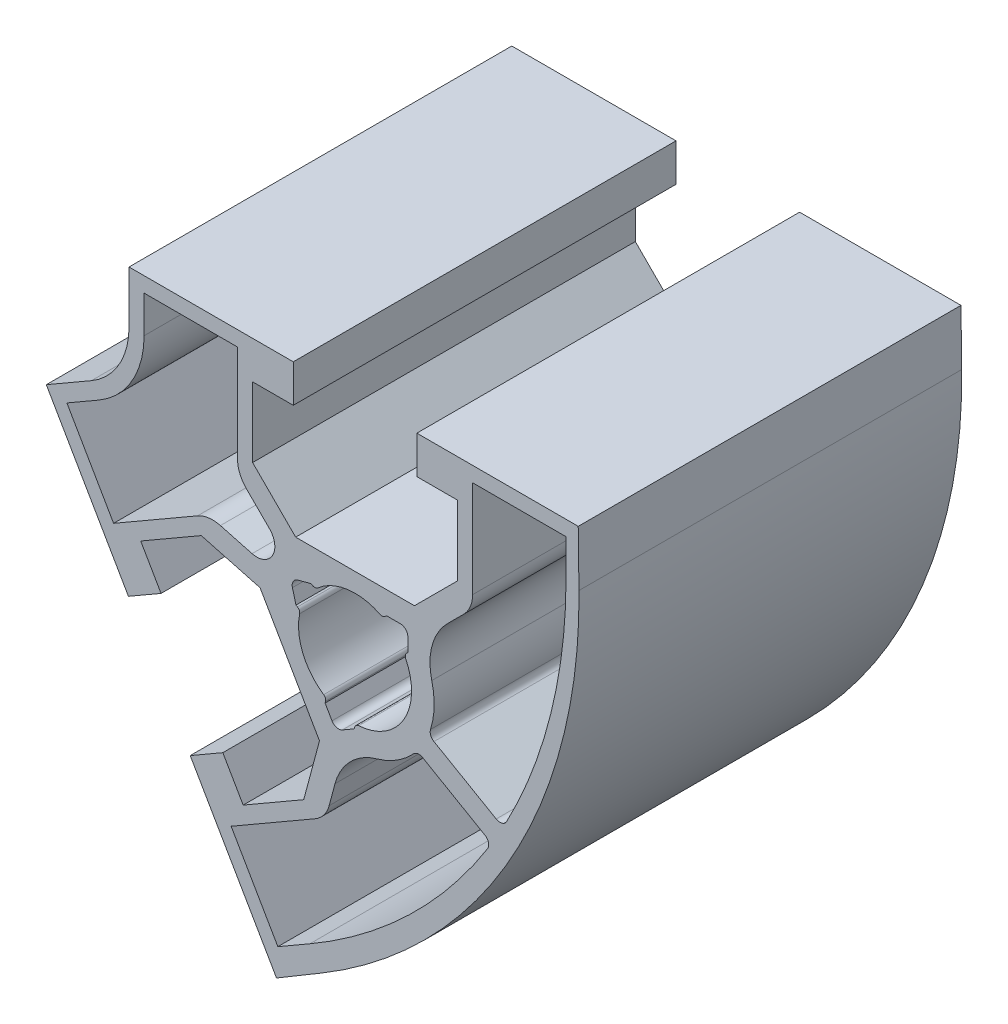
from build123d import *

# Parameters (mm, degrees)
EXTRUSION4_DEPTH = 25.4


with BuildPart() as part:
    # Sketch1 → Extrusion4 (new body)
    with BuildSketch(Plane.XY):
        with BuildLine():
            Line((-14.999999918, 14.999999985), (-4.099998388, 14.999999985))
            Line((-4.099998388, 14.999999985), (-4.099998388, 12.499999985))
            Line((-4.099998388, 12.499999985), (-6.799995338, 12.499999985))
            Line((-6.799995338, 12.499999985), (-6.799995338, 7.860655585))
            Line((-6.799995338, 7.860655585), (-3.941497908, 5.002158155))
            Line((-3.941497908, 5.002158155), (3.941498082, 5.002158155))
            Line((3.941498082, 5.002158155), (6.799995512, 7.860655585))
            Line((6.799995512, 7.860655585), (6.799995512, 12.499999985))
            Line((6.799995512, 12.499999985), (4.099998562, 12.499999985))
            Line((4.099998562, 12.499999985), (4.099998562, 14.999999985))
            Line((4.099998562, 14.999999985), (14.810114901, 14.999999985))
            Line((14.810114901, 14.999999985), (14.858211116, 11.334807121))
            ThreePointArc((14.858211116, 11.334807121), (10.399126577, -6.225213544), (-2.242564242, -19.203095263))
            Line((-2.242564242, -19.203095263), (-5.213160142, -20.9705416))
            Line((-5.213160142, -20.9705416), (-10.940381729, -11.050702829))
            Line((-10.940381729, -11.050702829), (-8.775318226, -9.800702836))
            Line((-8.775318226, -9.800702836), (-7.425319757, -12.138968783))
            Line((-7.425319757, -12.138968783), (-3.407529648, -9.819296585))
            Line((-3.407529648, -9.819296585), (-2.361246978, -5.914516485))
            Line((-2.361246978, -5.914516485), (-6.302744968, 0.912358295))
            Line((-6.302744968, 0.912358295), (-10.207525068, 1.958640965))
            Line((-10.207525068, 1.958640965), (-14.225315169, -0.361031229))
            Line((-14.225315169, -0.361031229), (-12.875316699, -2.699297177))
            Line((-12.875316699, -2.699297177), (-15.040380206, -3.949297173))
            Line((-15.040380206, -3.949297173), (-20.490380962, 5.490381032))
            Line((-20.490380962, 5.490381032), (-17.499999918, 7.216878355))
            ThreePointArc((-17.499999918, 7.216878355), (-15.669872899, 9.047005374), (-14.999999918, 11.547005375))
            Line((-14.999999918, 11.547005375), (-14.999999918, 14.999999985))
        make_face()
        with BuildLine():
            Line((-3.803644053, 2.604283261), (-2.920581563, 2.840899141))
            Line((-2.920581563, 2.840899141), (-2.821802903, 2.783869251))
            ThreePointArc((-2.821802903, 2.783869251), (-2.642326542, 2.745128481), (-2.473891573, 2.818219331))
            ThreePointArc((-2.473891573, 2.818219331), (-0.48947315, 3.717918241), (1.660187067, 3.362481111))
            ThreePointArc((1.660187067, 3.362481111), (1.841800057, 3.335474951), (2.005134057, 3.419347561))
            Line((2.005134057, 3.419347561), (2.085786497, 3.500000001))
            Line((2.085786497, 3.500000001), (3.000000057, 3.500000001))
            ThreePointArc((3.000000057, 3.500000001), (3.353553447, 3.353553391), (3.500000057, 3.000000001))
            Line((3.500000057, 3.000000001), (3.500000057, 2.085786441))
            Line((3.500000057, 2.085786441), (3.419347617, 2.005134001))
            ThreePointArc((3.419347617, 2.005134001), (3.335475004, 1.841799992), (3.362481172, 1.660186995))
            ThreePointArc((3.362481172, 1.660186995), (3.247595339, -1.874999996), (0.243476512, -3.742087545))
            ThreePointArc((0.243476512, -3.742087545), (0.072691963, -3.809506014), (-0.026823118, -3.963808835))
            Line((-0.026823118, -3.963808835), (-0.056343958, -4.073982115))
            Line((-0.056343958, -4.073982115), (-0.848076128, -4.531088895))
            ThreePointArc((-0.848076128, -4.531088895), (-1.227485649, -4.581039105), (-1.531088828, -4.348076195))
            Line((-1.531088828, -4.348076195), (-1.988195608, -3.556344025))
            Line((-1.988195608, -3.556344025), (-1.958674768, -3.446170745))
            ThreePointArc((-1.958674768, -3.446170745), (-1.967705959, -3.262783044), (-2.081900468, -3.119004655))
            ThreePointArc((-2.081900468, -3.119004655), (-3.464548158, -1.435062862), (-3.677595258, 0.733343355))
            ThreePointArc((-3.677595258, 0.733343355), (-3.698514209, 0.915757746), (-3.821802888, 1.051818445))
            Line((-3.821802888, 1.051818445), (-3.920581548, 1.108848335))
            Line((-3.920581548, 1.108848335), (-4.157197428, 1.991910825))
            ThreePointArc((-4.157197428, 1.991910825), (-4.10724722, 2.371320342), (-3.803644053, 2.604283261))
        make_face(mode=Mode.SUBTRACT)
        with BuildLine():
            Line((-13.999999918, 11.547005365), (-13.999999918, 13.999999985))
            Line((-13.999999918, 13.999999985), (-7.799995348, 13.999999985))
            Line((-7.799995348, 13.999999985), (-7.799995348, 7.567762365))
            ThreePointArc((-7.799995348, 7.567762365), (-7.647754416, 6.802395499), (-7.214208908, 6.153548805))
            Line((-7.214208908, 6.153548805), (-5.676298958, 4.615638855))
            ThreePointArc((-5.676298958, 4.615638855), (-5.485596608, 3.167110716), (-6.835409948, 2.607999725))
            Line((-6.835409948, 2.607999725), (-8.936234008, 3.170913835))
            ThreePointArc((-8.936234008, 3.170913835), (-9.714924484, 3.221951904), (-10.453872098, 2.971112985))
            Line((-10.453872098, 2.971112985), (-16.024353279, -0.245005824))
            Line((-16.024353279, -0.245005824), (-19.124355567, 5.124355624))
            Line((-19.124355567, 5.124355624), (-16.999999918, 6.350852945))
            ThreePointArc((-16.999999918, 6.350852945), (-14.803847494, 8.547005366), (-13.999999918, 11.547005365))
        make_face(mode=Mode.SUBTRACT)
        with BuildLine():
            Line((7.799995502, 7.567762365), (7.799995491, 13.999999985))
            Line((7.799995491, 13.999999985), (14.000000062, 13.999999985))
            Line((14.000000062, 13.999999985), (14.000000062, 11.547005385))
            ThreePointArc((14.000000062, 11.547005385), (12.9999649, 3.361510856), (10.058687082, -4.342467065))
            ThreePointArc((10.058687082, -4.342467065), (9.755046631, -4.589262395), (9.366647572, -4.541811055))
            Line((9.366647572, -4.541811055), (5.235555602, -2.156723995))
            ThreePointArc((5.235555602, -2.156723995), (5.019640061, -1.905157444), (5.008550772, -1.573823355))
            ThreePointArc((5.008550772, -1.573823355), (5.247767117, -0.153104957), (5.091786812, 1.279143405))
            ThreePointArc((5.091786812, 1.279143405), (5.115772962, 3.319255937), (6.142816242, 5.082155985))
            Line((6.142816242, 5.082155985), (7.214209062, 6.153548805))
            ThreePointArc((7.214209062, 6.153548805), (7.647754561, 6.802395503), (7.799995502, 7.567762365))
        make_face(mode=Mode.SUBTRACT)
        with BuildLine():
            Line((-1.722025028, -9.324462665), (-1.329868038, -7.860912855))
            ThreePointArc((-1.329868038, -7.860912855), (-0.316673452, -6.090017259), (1.438122752, -5.049188375))
            ThreePointArc((1.438122752, -5.049188375), (2.756476373, -4.4681471), (3.867246431, -3.550620473))
            ThreePointArc((3.867246431, -3.550620473), (4.159734815, -3.394557032), (4.485555611, -3.455762103))
            Line((4.485555611, -3.455762103), (8.616647581, -5.840849163))
            ThreePointArc((8.616647581, -5.840849163), (8.851941182, -6.153486949), (8.790030382, -6.539844965))
            ThreePointArc((8.790030382, -6.539844965), (3.588828705, -12.939055237), (-2.999999918, -17.897858355))
            Line((-2.999999918, -17.897858355), (-5.124355566, -19.12435565))
            Line((-5.124355566, -19.12435565), (-8.224357859, -13.754994194))
            Line((-8.224357859, -13.754994194), (-2.653876678, -10.538875385))
            ThreePointArc((-2.653876678, -10.538875385), (-2.067169998, -10.024347435), (-1.722025028, -9.324462665))
        make_face(mode=Mode.SUBTRACT)
    extrude(amount=EXTRUSION4_DEPTH)


solid = part.part
